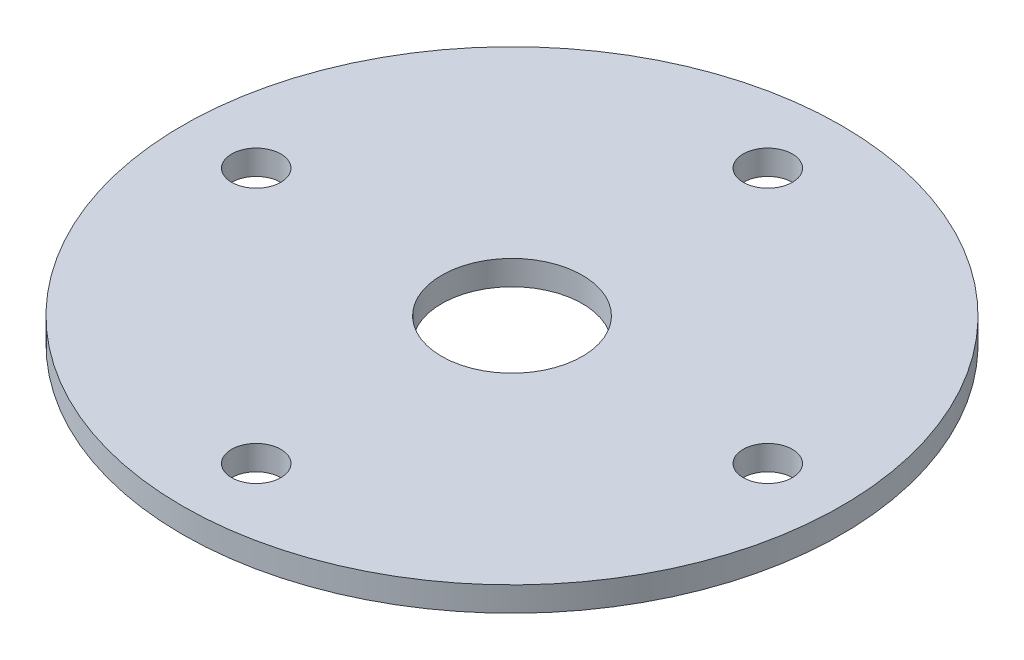
from build123d import *

# Parameters (mm, degrees)
SKETCH1_R               = 67
SKETCH1_R_2             = 5
BOSS_EXTRUDE1_DEPTH     = 5
CUT_EXTRUDE3_DEPTH      = 95.884139876
CUT_EXTRUDE3_DEPTH_BACK = 95.884139876
SKETCH2_4_R             = 14.3


with BuildPart() as part:
    # Sketch1 → Boss-Extrude1 (new body)
    with BuildSketch(Plane(origin=(0, 0, 0), x_dir=(1, 0, 0), z_dir=(0, 1, 0))):
        Circle(SKETCH1_R)
        with BuildLine():
            ThreePointArc((5, -52), (-3.535533906, -55.535533906), (0, -47))
            ThreePointArc((0, -47), (3.535533906, -48.464466094), (5, -52))
        make_face(mode=Mode.SUBTRACT)
        with Locations((-52, 0)):
            Circle(SKETCH1_R_2, mode=Mode.SUBTRACT)
        with Locations((52, 0)):
            Circle(SKETCH1_R_2, mode=Mode.SUBTRACT)
        with BuildLine():
            ThreePointArc((5, 52), (3.535533906, 48.464466094), (0, 47))
            ThreePointArc((0, 47), (-3.535533906, 55.535533906), (5, 52))
        make_face(mode=Mode.SUBTRACT)
    extrude(amount=BOSS_EXTRUDE1_DEPTH)

    # Sketch2_4 → Cut-Extrude3 (cut, two sides: drawn at the far end of the back side and taken through both)
    with BuildSketch(Plane(origin=(0, 5, 0), x_dir=(1, 0, 0), z_dir=(0, 1, 0)).offset(-CUT_EXTRUDE3_DEPTH_BACK)):
        Circle(SKETCH2_4_R)
    extrude(amount=CUT_EXTRUDE3_DEPTH + CUT_EXTRUDE3_DEPTH_BACK, mode=Mode.SUBTRACT)


solid = part.part
